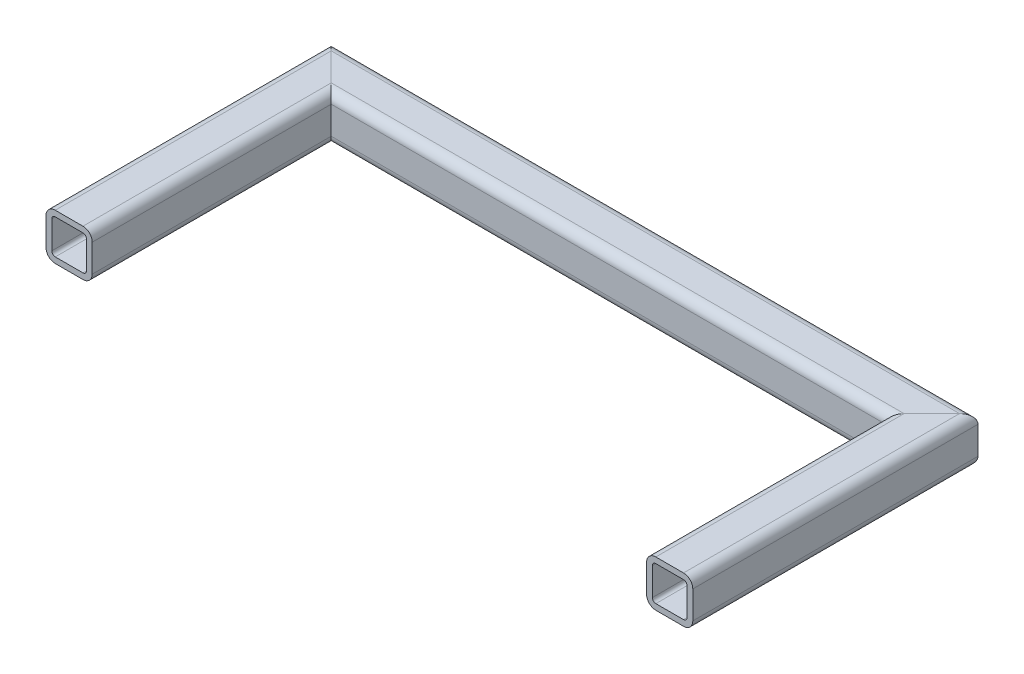
from build123d import *

# Parameters (mm, degrees)
SQUARE_TUBING_1_X_1_X_0_125_1_DEPTH        = 163.080112242
SQUARE_TUBING_1_X_1_X_0_125_1_2_DEPTH      = 349.160512242
SQUARE_TUBING_1_X_1_X_0_125_1_2_DEPTH_BACK = 18.960512242
SQUARE_TUBING_1_X_1_X_0_125_1_3_DEPTH      = 163.080112242


with BuildPart() as part:
    # Sketch12 on segment 1 (carried to segment 1) → Square tubing 1 X 1 X 0.125(1) (new body)
    with BuildSketch(Plane(origin=(-220.377072335, 0, 67.561808122), x_dir=(-1, 0, 0), z_dir=(0, 0, -1))):
        with BuildLine():
            Line((-7.62, -12.7), (7.62, -12.7))
            ThreePointArc((7.62, -12.7), (11.212102448, -11.212102448), (12.7, -7.62))
            Line((12.7, -7.62), (12.7, 7.62))
            ThreePointArc((12.7, 7.62), (11.212102448, 11.212102448), (7.62, 12.7))
            Line((7.62, 12.7), (-7.62, 12.7))
            ThreePointArc((-7.62, 12.7), (-11.212102448, 11.212102448), (-12.7, 7.62))
            Line((-12.7, 7.62), (-12.7, -7.62))
            ThreePointArc((-12.7, -7.62), (-11.212102448, -11.212102448), (-7.62, -12.7))
        make_face()
        with BuildLine():
            Line((-7.62, -9.525), (7.62, -9.525))
            ThreePointArc((7.62, -9.525), (8.967038418, -8.967038418), (9.525, -7.62))
            Line((9.525, -7.62), (9.525, 7.62))
            ThreePointArc((9.525, 7.62), (8.967038418, 8.967038418), (7.62, 9.525))
            Line((7.62, 9.525), (-7.62, 9.525))
            ThreePointArc((-7.62, 9.525), (-8.967038418, 8.967038418), (-9.525, 7.62))
            Line((-9.525, 7.62), (-9.525, -7.62))
            ThreePointArc((-9.525, -7.62), (-8.967038418, -8.967038418), (-7.62, -9.525))
        make_face(mode=Mode.SUBTRACT)
    extrude(amount=SQUARE_TUBING_1_X_1_X_0_125_1_DEPTH)

    # Square tubing 1 X 1 X 0.125(1) mitre 1
    split(bisect_by=Plane(origin=(-220.377072335, 0, -76.557791878), x_dir=(0, -1, 0), z_dir=(-0.707106781, 0, 0.707106781)), keep=Keep.TOP)


with BuildPart() as body_2:
    # Sketch12 → Square tubing 1 X 1 X 0.125_1 2 (new, two sides)
    with BuildSketch(Plane(origin=(-220.377072335, 0, -76.557791878), x_dir=(0, 0, -1), z_dir=(1, 0, 0))) as square_tubing_1_x_1_x_0_125_1_2_sk:
        with BuildLine():
            Line((-7.62, -12.7), (7.62, -12.7))
            ThreePointArc((7.62, -12.7), (11.212102448, -11.212102448), (12.7, -7.62))
            Line((12.7, -7.62), (12.7, 7.62))
            ThreePointArc((12.7, 7.62), (11.212102448, 11.212102448), (7.62, 12.7))
            Line((7.62, 12.7), (-7.62, 12.7))
            ThreePointArc((-7.62, 12.7), (-11.212102448, 11.212102448), (-12.7, 7.62))
            Line((-12.7, 7.62), (-12.7, -7.62))
            ThreePointArc((-12.7, -7.62), (-11.212102448, -11.212102448), (-7.62, -12.7))
        make_face()
        with BuildLine():
            Line((-7.62, -9.525), (7.62, -9.525))
            ThreePointArc((7.62, -9.525), (8.967038418, -8.967038418), (9.525, -7.62))
            Line((9.525, -7.62), (9.525, 7.62))
            ThreePointArc((9.525, 7.62), (8.967038418, 8.967038418), (7.62, 9.525))
            Line((7.62, 9.525), (-7.62, 9.525))
            ThreePointArc((-7.62, 9.525), (-8.967038418, 8.967038418), (-9.525, 7.62))
            Line((-9.525, 7.62), (-9.525, -7.62))
            ThreePointArc((-9.525, -7.62), (-8.967038418, -8.967038418), (-7.62, -9.525))
        make_face(mode=Mode.SUBTRACT)
    extrude(amount=SQUARE_TUBING_1_X_1_X_0_125_1_2_DEPTH)
    extrude(square_tubing_1_x_1_x_0_125_1_2_sk.sketch, amount=-SQUARE_TUBING_1_X_1_X_0_125_1_2_DEPTH_BACK)

    # Square tubing 1 X 1 X 0.125_1 2 mitre 1
    split(bisect_by=Plane(origin=(-220.377072335, 0, -76.557791878), x_dir=(0, 1, 0), z_dir=(0.707106781, 0, -0.707106781)), keep=Keep.TOP)

    # Square tubing 1 X 1 X 0.125_1 2 mitre 2
    split(bisect_by=Plane(origin=(109.822927665, 0, -76.557791878), x_dir=(0, -1, 0), z_dir=(-0.707106781, 0, -0.707106781)), keep=Keep.TOP)


with BuildPart() as body_3:
    # Sketch12 on segment 3 (carried to segment 3) → Square tubing 1 X 1 X 0.125_1 3 (new body)
    with BuildSketch(Plane(origin=(109.822927665, 0, -95.51830412), x_dir=(1, 0, 0), z_dir=(0, 0, 1))):
        with BuildLine():
            Line((-7.62, -12.7), (7.62, -12.7))
            ThreePointArc((7.62, -12.7), (11.212102448, -11.212102448), (12.7, -7.62))
            Line((12.7, -7.62), (12.7, 7.62))
            ThreePointArc((12.7, 7.62), (11.212102448, 11.212102448), (7.62, 12.7))
            Line((7.62, 12.7), (-7.62, 12.7))
            ThreePointArc((-7.62, 12.7), (-11.212102448, 11.212102448), (-12.7, 7.62))
            Line((-12.7, 7.62), (-12.7, -7.62))
            ThreePointArc((-12.7, -7.62), (-11.212102448, -11.212102448), (-7.62, -12.7))
        make_face()
        with BuildLine():
            Line((-7.62, -9.525), (7.62, -9.525))
            ThreePointArc((7.62, -9.525), (8.967038418, -8.967038418), (9.525, -7.62))
            Line((9.525, -7.62), (9.525, 7.62))
            ThreePointArc((9.525, 7.62), (8.967038418, 8.967038418), (7.62, 9.525))
            Line((7.62, 9.525), (-7.62, 9.525))
            ThreePointArc((-7.62, 9.525), (-8.967038418, 8.967038418), (-9.525, 7.62))
            Line((-9.525, 7.62), (-9.525, -7.62))
            ThreePointArc((-9.525, -7.62), (-8.967038418, -8.967038418), (-7.62, -9.525))
        make_face(mode=Mode.SUBTRACT)
    extrude(amount=SQUARE_TUBING_1_X_1_X_0_125_1_3_DEPTH)

    # Square tubing 1 X 1 X 0.125_1 3 mitre 1
    split(bisect_by=Plane(origin=(109.822927665, 0, -76.557791878), x_dir=(0, 1, 0), z_dir=(0.707106781, 0, 0.707106781)), keep=Keep.TOP)


solid = Compound([part.part, body_2.part, body_3.part])
